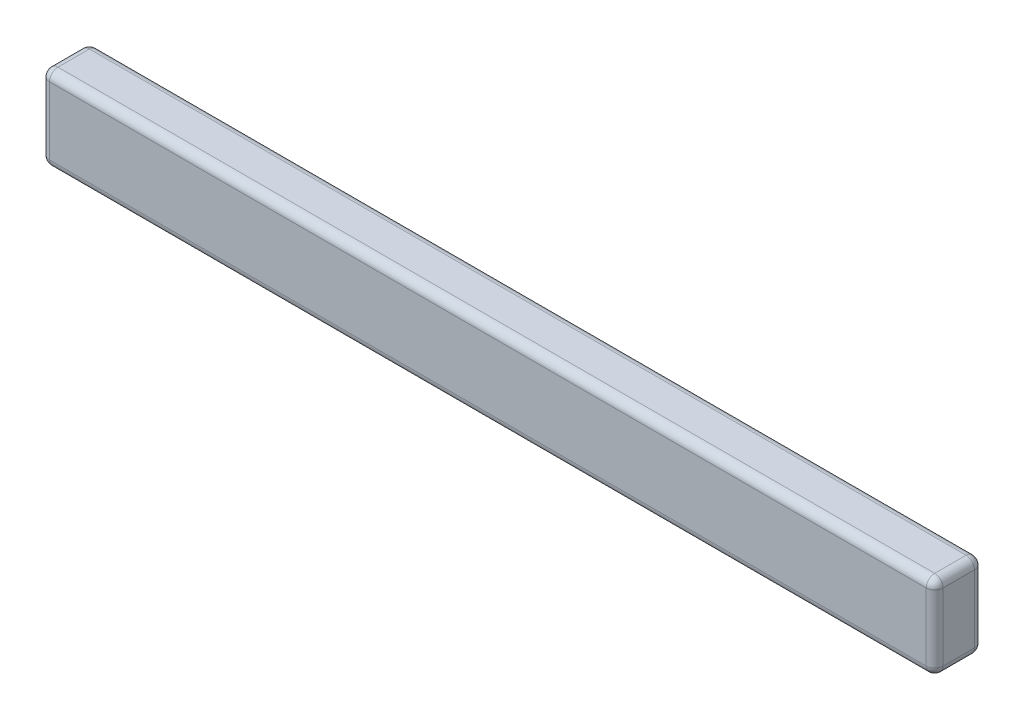
from build123d import *

# Parameters (mm, degrees)
SKETCH1_W           = 3700
SKETCH1_H           = 350
BOSS_EXTRUDE2_DEPTH = 200
FILLET1_R           = 35


with BuildPart() as part:
    # Sketch1 → Boss-Extrude2 (new body)
    with BuildSketch(Plane.XY):
        with Locations((549.839539078, -499.547034379)):
            Rectangle(SKETCH1_W, SKETCH1_H)
    extrude(amount=BOSS_EXTRUDE2_DEPTH)

    # Fillet1
    fillet1_edges = [part.edges().sort_by_distance(p)[0] for p in [
        (-1300.160460922, -499.547034379, 200),
        (549.839539078, -674.547034379, 200),
        (2399.839539078, -499.547034379, 200),
        (549.839539078, -674.547034379, 0),
        (-1300.160460922, -499.547034379, 0),
        (549.839539078, -324.547034379, 0),
        (2399.839539078, -499.547034379, 0),
        (2399.839539078, -674.547034379, 100),
        (-1300.160460922, -674.547034379, 100),
        (-1300.160460922, -324.547034379, 100),
        (2399.839539078, -324.547034379, 100),
        (549.839539078, -324.547034379, 200),
    ]]
    fillet(fillet1_edges, radius=FILLET1_R)


solid = part.part
